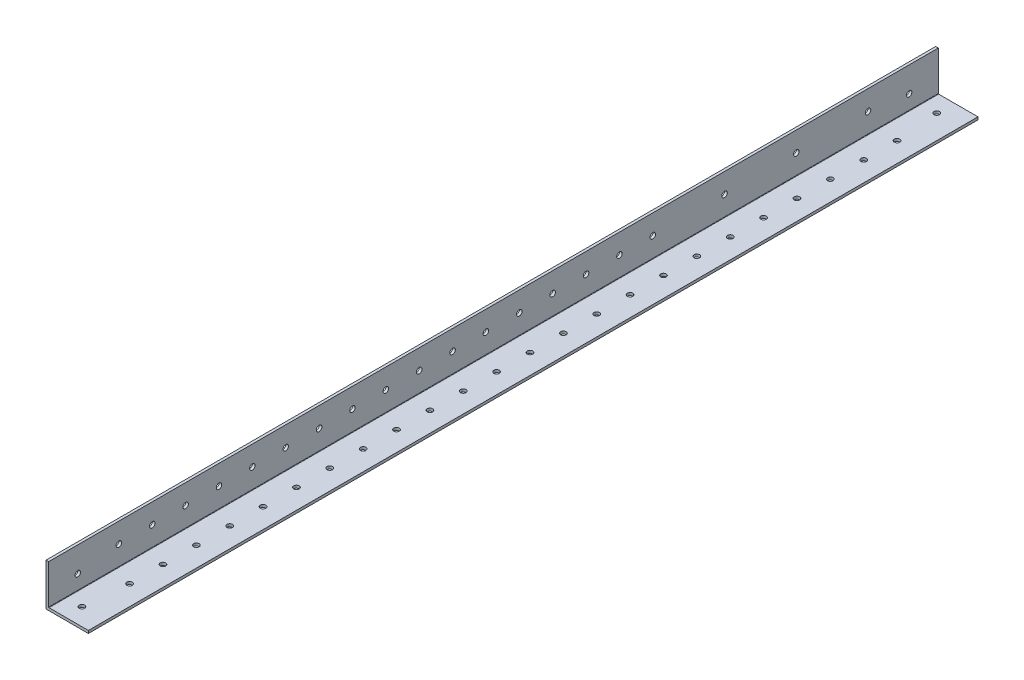
from build123d import *

# Parameters (mm, degrees)
BOSS_EXTRUDE1_DEPTH = 1219.2
FILLET1_R           = 0.254
SKETCH4_W           = 1905.2
SKETCH4_H           = 92.573708452
CUT_EXTRUDE1_DEPTH  = 60
SKETCH9_R           = 1.65
CUT_EXTRUDE6_DEPTH  = 60
SKETCH10_R          = 1.65
CUT_EXTRUDE7_DEPTH  = 60


with BuildPart() as part:
    # Sketch3 → Boss-Extrude1 (new, symmetric)
    with BuildSketch(Plane.XY):
        Polygon((1.5875, 25.4), (0, 25.4), (0, 0), (25.4, 0), (25.4, 1.5875), (1.5875, 1.5875), align=None)
    extrude(amount=BOSS_EXTRUDE1_DEPTH, both=True)

    # Fillet1
    fillet1_edges = [part.edges().sort_by_distance(p)[0] for p in [
        (1.5875, 1.5875, 0),
    ]]
    fillet(fillet1_edges, radius=FILLET1_R)

    # Sketch4 → Cut-Extrude1 (cut)
    with BuildSketch(Plane.ZY):
        with Locations((-266.6, -7.427787689)):
            Rectangle(SKETCH4_W, SKETCH4_H)
    extrude(amount=-CUT_EXTRUDE1_DEPTH, mode=Mode.SUBTRACT)

    # Sketch9 → Cut-Extrude6 (cut)
    with BuildSketch(Plane(origin=(0, 1.5875, 0), x_dir=(1, 0, 0), z_dir=(0, 1, 0))):
        with Locations(Location((11.113, -1208.791795667, 0), (0, 0, 180))):
            Circle(SKETCH9_R)
        with Locations(Location((11.1125, -696.408204333, 0), (0, 0, 180))):
            Circle(SKETCH9_R)
        with Locations(Location((13.49375, -1182.6, 0), (0, 0, 180))):
            Circle(SKETCH9_R)
        with Locations(Location((13.49375, -1162.6, 0), (0, 0, 180))):
            Circle(SKETCH9_R)
        with Locations(Location((13.49375, -1142.6, 0), (0, 0, 180))):
            Circle(SKETCH9_R)
        with Locations(Location((13.49375, -1122.6, 0), (0, 0, 180))):
            Circle(SKETCH9_R)
        with Locations(Location((13.49375, -1102.6, 0), (0, 0, 180))):
            Circle(SKETCH9_R)
        with Locations(Location((13.49375, -1082.6, 0), (0, 0, 180))):
            Circle(SKETCH9_R)
        with Locations(Location((13.49375, -1062.6, 0), (0, 0, 180))):
            Circle(SKETCH9_R)
        with Locations(Location((13.49375, -1042.6, 0), (0, 0, 180))):
            Circle(SKETCH9_R)
        with Locations(Location((13.49375, -1022.6, 0), (0, 0, 180))):
            Circle(SKETCH9_R)
        with Locations(Location((13.49375, -1002.6, 0), (0, 0, 180))):
            Circle(SKETCH9_R)
        with Locations(Location((13.49375, -982.6, 0), (0, 0, 180))):
            Circle(SKETCH9_R)
        with Locations(Location((13.49375, -962.6, 0), (0, 0, 180))):
            Circle(SKETCH9_R)
        with Locations(Location((13.49375, -942.6, 0), (0, 0, 180))):
            Circle(SKETCH9_R)
        with Locations(Location((13.49375, -922.6, 0), (0, 0, 180))):
            Circle(SKETCH9_R)
        with Locations(Location((13.49375, -902.6, 0), (0, 0, 180))):
            Circle(SKETCH9_R)
        with Locations(Location((13.49375, -882.6, 0), (0, 0, 180))):
            Circle(SKETCH9_R)
        with Locations(Location((13.49375, -862.6, 0), (0, 0, 180))):
            Circle(SKETCH9_R)
        with Locations(Location((13.49375, -842.6, 0), (0, 0, 180))):
            Circle(SKETCH9_R)
        with Locations(Location((13.49375, -822.6, 0), (0, 0, 180))):
            Circle(SKETCH9_R)
        with Locations(Location((13.49375, -802.6, 0), (0, 0, 180))):
            Circle(SKETCH9_R)
        with Locations(Location((13.49375, -782.6, 0), (0, 0, 180))):
            Circle(SKETCH9_R)
        with Locations(Location((13.49375, -762.6, 0), (0, 0, 180))):
            Circle(SKETCH9_R)
        with Locations(Location((13.49375, -742.6, 0), (0, 0, 180))):
            Circle(SKETCH9_R)
        with Locations(Location((13.49375, -722.6, 0), (0, 0, 180))):
            Circle(SKETCH9_R)
    extrude(amount=-CUT_EXTRUDE6_DEPTH, mode=Mode.SUBTRACT)

    # Sketch10 → Cut-Extrude7 (cut)
    with BuildSketch(Plane(origin=(1.5875, 0, 0), x_dir=(0, 0, -1), z_dir=(1, 0, 0))):
        with Locations((-703.4625, 10.3759)):
            Circle(SKETCH10_R)
        with Locations((-1201.7375, 10.3759)):
            Circle(SKETCH10_R)
        with Locations((-728.1, 13.49375)):
            Circle(SKETCH10_R)
        with Locations((-771.1, 13.49375)):
            Circle(SKETCH10_R)
        with Locations((-814.1, 13.49375)):
            Circle(SKETCH10_R)
        with Locations((-857.1, 13.49375)):
            Circle(SKETCH10_R)
        with Locations((-877.1, 13.49375)):
            Circle(SKETCH10_R)
        with Locations((-897.1, 13.49375)):
            Circle(SKETCH10_R)
        with Locations((-917.1, 13.49375)):
            Circle(SKETCH10_R)
        with Locations((-937.1, 13.49375)):
            Circle(SKETCH10_R)
        with Locations((-957.1, 13.49375)):
            Circle(SKETCH10_R)
        with Locations((-977.1, 13.49375)):
            Circle(SKETCH10_R)
        with Locations((-997.1, 13.49375)):
            Circle(SKETCH10_R)
        with Locations((-1017.1, 13.49375)):
            Circle(SKETCH10_R)
        with Locations((-1037.1, 13.49375)):
            Circle(SKETCH10_R)
        with Locations((-1057.1, 13.49375)):
            Circle(SKETCH10_R)
        with Locations((-1077.1, 13.49375)):
            Circle(SKETCH10_R)
        with Locations((-1097.1, 13.49375)):
            Circle(SKETCH10_R)
        with Locations((-1117.1, 13.49375)):
            Circle(SKETCH10_R)
        with Locations((-1137.1, 13.49375)):
            Circle(SKETCH10_R)
        with Locations((-1157.1, 13.49375)):
            Circle(SKETCH10_R)
        with Locations((-1177.1, 13.49375)):
            Circle(SKETCH10_R)
    extrude(amount=-CUT_EXTRUDE7_DEPTH, mode=Mode.SUBTRACT)


solid = part.part
